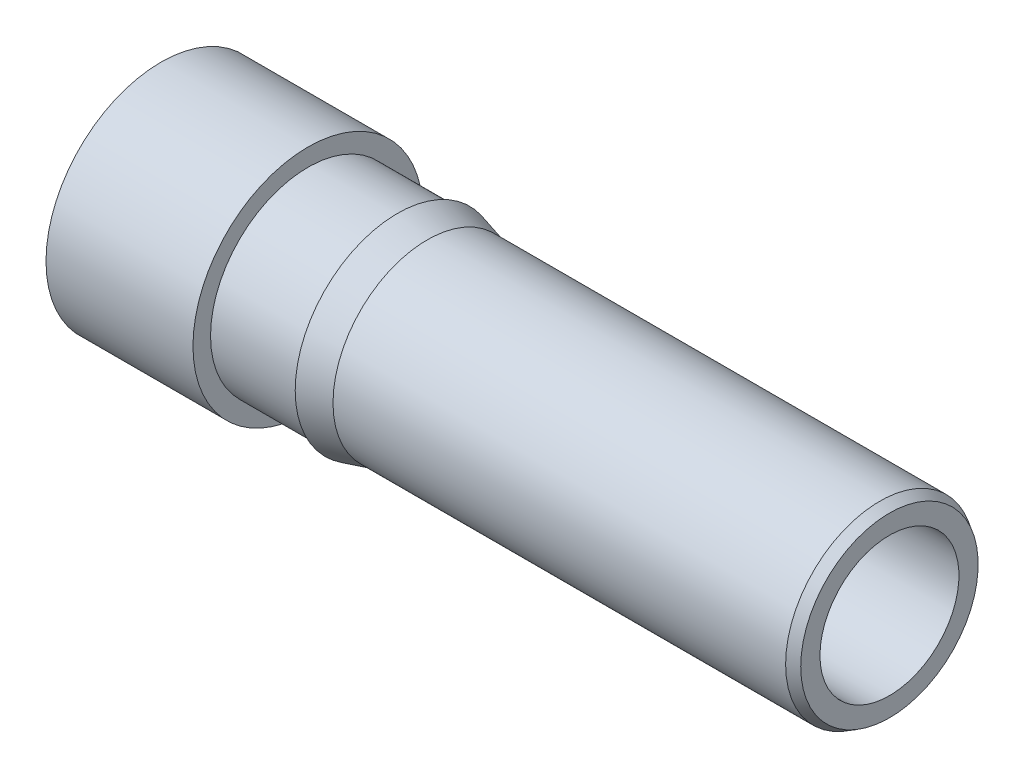
from build123d import *

# Parameters (mm, degrees)
HOLE1_D     = 1.2954
HOLE1_DEPTH = 3.0226
HOLE1_TIP   = 0.389177423
HOLE2_D     = 1.1049
HOLE2_DEPTH = 5.7912
HOLE2_TIP   = 0.331945449


with BuildPart() as part:
    # Sketch1 → RevolutionAngle1 (revolve)
    with BuildSketch(Plane.XY):
        Polygon((0, 0), (0, 0.9144), (1.1684, 0.9144), (1.1684, 0.7747), (1.8796, 0.7747), (1.8796, 0.8128), (2.116585226, 0.7493), (5.715, 0.7493), (5.7912, 0.705305909), (5.7912, 0), align=None)
    revolve(axis=Axis((0, 0, 0), (1, 0, 0)))

    # Hole1
    with Locations(Plane.ZY):
        with Locations((0, 0)):
            Hole(HOLE1_D / 2, depth=HOLE1_DEPTH)
            with Locations((0, 0, -(HOLE1_DEPTH + HOLE1_TIP / 2))):  # 118° drill point
                Cone(0, HOLE1_D / 2, HOLE1_TIP, mode=Mode.SUBTRACT)

    # Hole2
    with Locations(Plane(origin=(0, 0.189503468, -0.794290882), x_dir=(0, 0, 1), z_dir=(-1, 0, 0))):
        with Locations((0.794290882, -0.189503468)):
            Hole(HOLE2_D / 2, depth=HOLE2_DEPTH)
            with Locations((0, 0, -(HOLE2_DEPTH + HOLE2_TIP / 2))):  # 118° drill point
                Cone(0, HOLE2_D / 2, HOLE2_TIP, mode=Mode.SUBTRACT)


solid = part.part
